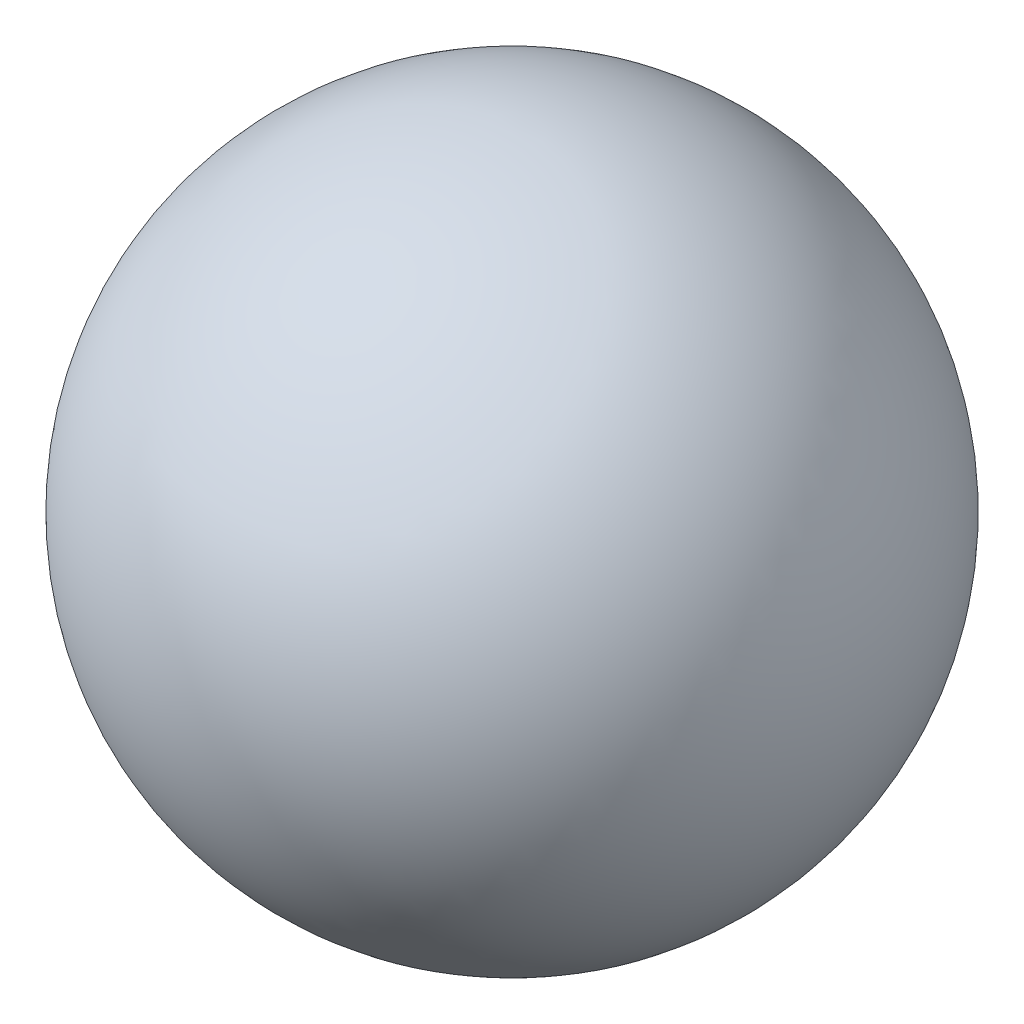
from build123d import *


with BuildPart() as part:
    # Sketch2 → Revolve1 (revolve)
    with BuildSketch(Plane.XY):
        with BuildLine():
            Line((0, 2.38125), (0, -2.38125))
            ThreePointArc((0, -2.38125), (2.38125, 0), (0, 2.38125))
        make_face()
    revolve(axis=Axis((0, 2.38125, 0), (0, -1, 0)))


solid = part.part
